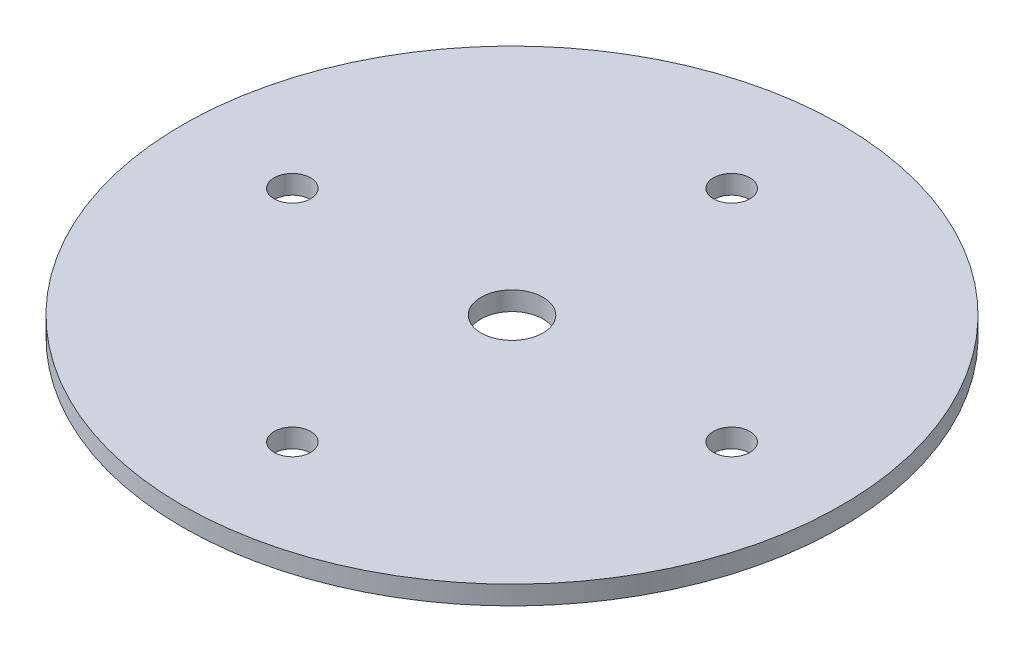
from build123d import *

# Parameters (mm, degrees)
SKETCH1_R           = 52.4
SKETCH1_R_2         = 4.925
SKETCH1_R_3         = 2.9
BOSS_EXTRUDE1_DEPTH = 3


with BuildPart() as part:
    # Sketch1 → Boss-Extrude1 (new body)
    with BuildSketch(Plane(origin=(0, 0, 0), x_dir=(1, 0, 0), z_dir=(0, 1, 0))):
        Circle(SKETCH1_R)
        Circle(SKETCH1_R_2, mode=Mode.SUBTRACT)
        with Locations((0, 34.925)):
            Circle(SKETCH1_R_3, mode=Mode.SUBTRACT)
        with Locations((34.925, 0)):
            Circle(SKETCH1_R_3, mode=Mode.SUBTRACT)
        with Locations((0, -34.925)):
            Circle(SKETCH1_R_3, mode=Mode.SUBTRACT)
        with Locations((-34.925, 0)):
            Circle(SKETCH1_R_3, mode=Mode.SUBTRACT)
    extrude(amount=BOSS_EXTRUDE1_DEPTH)


solid = part.part
